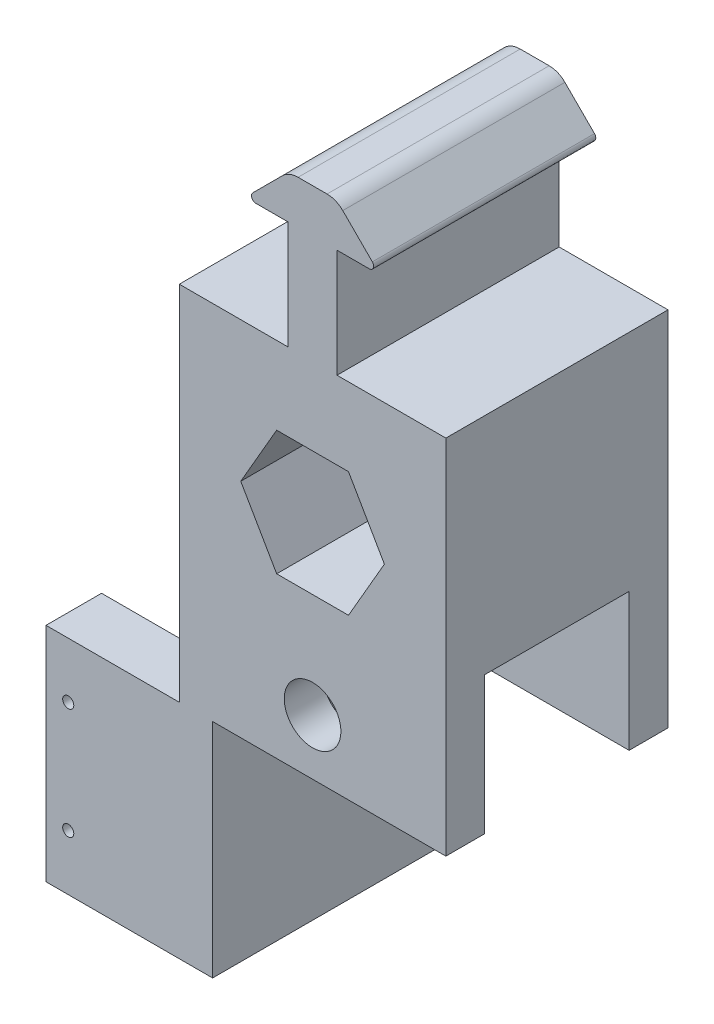
from build123d import *

# Parameters (mm, degrees)
BOSS_EXTRUDE1_DEPTH             = 12.7
BOSS_EXTRUDE4_REACH             = 14.7
BOSS_EXTRUDE4_DIRECTION_2_REACH = 14.7
SKETCH6_W                       = 16.51
SKETCH6_H                       = 15.748
CUT_EXTRUDE2_DEPTH              = 46.72
SKETCH11_W                      = 15.24
SKETCH11_H                      = 7.62
CUT_EXTRUDE3_DEPTH              = 3.81
SKETCH15_R                      = 3.2385
CUT_EXTRUDE4_DEPTH              = 25.4
SKETCH16_W                      = 6.35
SKETCH16_H                      = 21.59
BOSS_EXTRUDE5_DEPTH             = 15.24
SKETCH17_R                      = 0.635
CUT_EXTRUDE5_DEPTH              = 26.4


with BuildPart() as part:
    # Sketch1 → Boss-Extrude1 (new body, symmetric)
    with BuildSketch(Plane.XY):
        with BuildLine():
            Line((-15.24, 16.002), (-15.24, -25.4))
            Line((-15.24, -25.4), (15.24, -25.4))
            Line((15.24, -25.4), (15.24, 16.002))
            Line((15.24, 16.002), (2.794, 16.002))
            Line((2.794, 16.002), (2.794, 28.3845))
            Line((2.794, 28.3845), (6.477, 28.3845))
            ThreePointArc((6.477, 28.3845), (6.946330803, 28.698096816), (6.836210245, 29.251710245))
            Line((6.836210245, 29.251710245), (3.452459265, 32.635461224))
            ThreePointArc((3.452459265, 32.635461224), (2.628423959, 33.186064013), (1.656408041, 33.37941))
            Line((1.656408041, 33.37941), (-1.656408041, 33.37941))
            ThreePointArc((-1.656408041, 33.37941), (-2.628423959, 33.186064013), (-3.452459265, 32.635461224))
            Line((-3.452459265, 32.635461224), (-6.836210245, 29.251710245))
            ThreePointArc((-6.836210245, 29.251710245), (-6.946330803, 28.698096816), (-6.477, 28.3845))
            Line((-6.477, 28.3845), (-2.794, 28.3845))
            Line((-2.794, 28.3845), (-2.794, 16.002))
            Line((-2.794, 16.002), (-15.24, 16.002))
        make_face()
        Polygon((-4.106115114, 7.112), (-8.212230229, 0), (-4.106115114, -7.112), (4.106115114, -7.112), (8.212230229, 0), (4.106115114, 7.112), align=None, mode=Mode.SUBTRACT)
    extrude(amount=BOSS_EXTRUDE1_DEPTH, both=True)

    # Boss-Extrude4: up to this face of the body (flat: up to its plane)
    boss_extrude4_end = Plane(part.part.faces().sort_by_distance((-6.334610257, 28.951479763, 12.7))[0])
    # Sketch10 → Boss-Extrude4 (add, up to the picked face)
    with BuildSketch(Plane.XY, mode=Mode.PRIVATE) as boss_extrude4_sk1:
        Polygon((-15.24, -25.4), (-15.24, -46.99), (-30.48, -46.99), (-30.48, -50.8), (-11.43, -50.8), (-11.43, -25.4), align=None)
    boss_extrude4_tool1 = split(extrude(boss_extrude4_sk1.sketch, amount=BOSS_EXTRUDE4_REACH, mode=Mode.PRIVATE), bisect_by=boss_extrude4_end, keep=Keep.BOTH, mode=Mode.PRIVATE)
    add(boss_extrude4_tool1.solids().sort_by_distance((-14.9225, -36.195, 0))[0])

    # Boss-Extrude4 direction 2: up to this face of the body (flat: up to its plane)
    boss_extrude4_direction_2_end = Plane(part.part.faces().sort_by_distance((-6.334610257, 28.951479763, -12.7))[0])
    # Sketch10 → Boss-Extrude4 direction 2 (add, up to the picked face)
    with BuildSketch(Plane.XY, mode=Mode.PRIVATE) as boss_extrude4_direction_2_sk1:
        Polygon((-15.24, -25.4), (-15.24, -46.99), (-30.48, -46.99), (-30.48, -50.8), (-11.43, -50.8), (-11.43, -25.4), align=None)
    boss_extrude4_direction_2_tool1 = split(extrude(boss_extrude4_direction_2_sk1.sketch, amount=-BOSS_EXTRUDE4_DIRECTION_2_REACH, mode=Mode.PRIVATE), bisect_by=boss_extrude4_direction_2_end, keep=Keep.BOTH, mode=Mode.PRIVATE)
    add(boss_extrude4_direction_2_tool1.solids().sort_by_distance((-14.9225, -36.195, 0))[0])

    # Sketch6 → Cut-Extrude2 (cut, through all)
    with BuildSketch(Plane(origin=(15.24, 0, 0), x_dir=(0, 0, -1), z_dir=(1, 0, 0))):
        with Locations((0, -17.526)):
            Rectangle(SKETCH6_W, SKETCH6_H)
    extrude(amount=-CUT_EXTRUDE2_DEPTH, mode=Mode.SUBTRACT)

    # Sketch11 → Cut-Extrude3 (cut)
    with BuildSketch(Plane(origin=(0, -46.99, 0), x_dir=(1, 0, 0), z_dir=(0, 1, 0))):
        with Locations((-22.86, 0)):
            Rectangle(SKETCH11_W, SKETCH11_H)
    extrude(amount=-CUT_EXTRUDE3_DEPTH, mode=Mode.SUBTRACT)

    # Sketch15 → Cut-Extrude4 (cut)
    with BuildSketch(Plane.XY.offset(12.7)):
        with Locations((0, -19.05)):
            Circle(SKETCH15_R)
    extrude(amount=-CUT_EXTRUDE4_DEPTH, mode=Mode.SUBTRACT)

    # Sketch16 → Boss-Extrude5 (add)
    with BuildSketch(Plane.ZY.offset(15.24)):
        with Locations((9.525, -36.195)):
            Rectangle(SKETCH16_W, SKETCH16_H)
        with Locations((-9.525, -36.195)):
            Rectangle(SKETCH16_W, SKETCH16_H)
    extrude(amount=BOSS_EXTRUDE5_DEPTH)

    # Sketch17 → Cut-Extrude5 (cut, through all)
    with BuildSketch(Plane.XY.offset(12.7)):
        with Locations((-27.94, -31.75)):
            Circle(SKETCH17_R)
        with Locations((-27.94, -44.45)):
            Circle(SKETCH17_R)
    extrude(amount=-CUT_EXTRUDE5_DEPTH, mode=Mode.SUBTRACT)


solid = part.part
